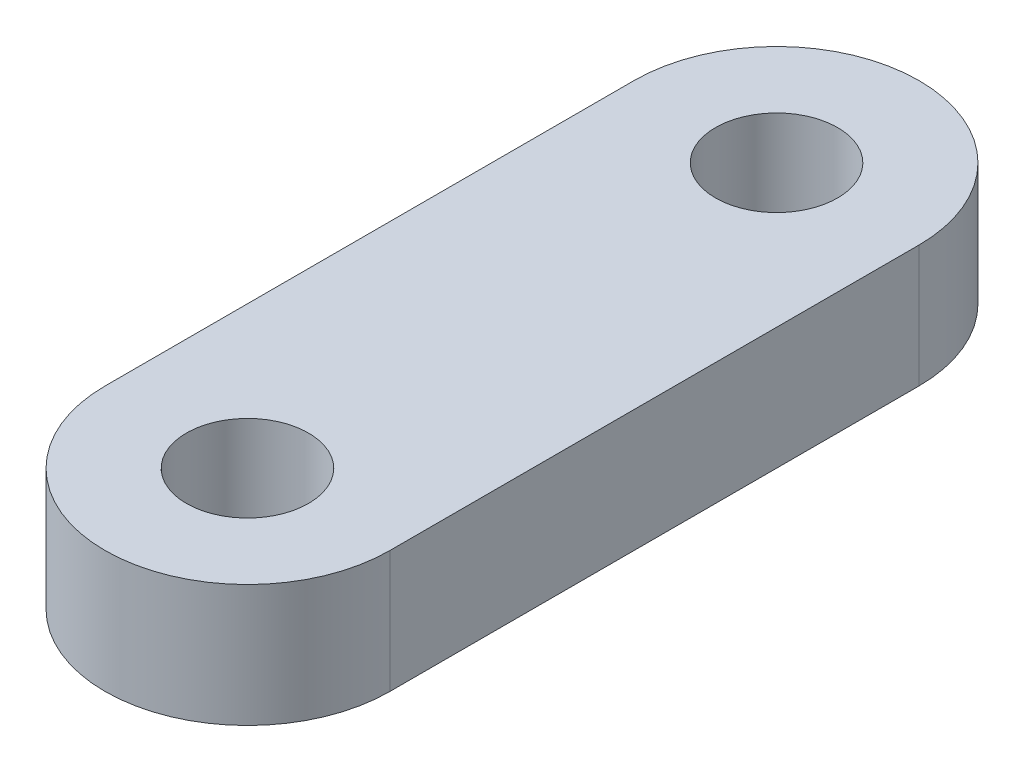
from build123d import *

# Parameters (mm, degrees)
SKETCH1_R           = 1.5
BOSS_EXTRUDE1_DEPTH = 1.5


with BuildPart() as part:
    # Sketch1 → Boss-Extrude1 (new body, symmetric)
    with BuildSketch(Plane(origin=(0, 0, 0), x_dir=(1, 0, 0), z_dir=(0, 1, 0))):
        with BuildLine():
            Line((-3.5, -6.5), (-3.5, 6.5))
            ThreePointArc((-3.5, 6.5), (0, 10), (3.5, 6.5))
            Line((3.5, 6.5), (3.5, -6.5))
            ThreePointArc((3.5, -6.5), (0, -10), (-3.5, -6.5))
        make_face()
        with Locations((0, 6.5)):
            Circle(SKETCH1_R, mode=Mode.SUBTRACT)
        with Locations((0, -6.5)):
            Circle(SKETCH1_R, mode=Mode.SUBTRACT)
    extrude(amount=BOSS_EXTRUDE1_DEPTH, both=True)


solid = part.part
